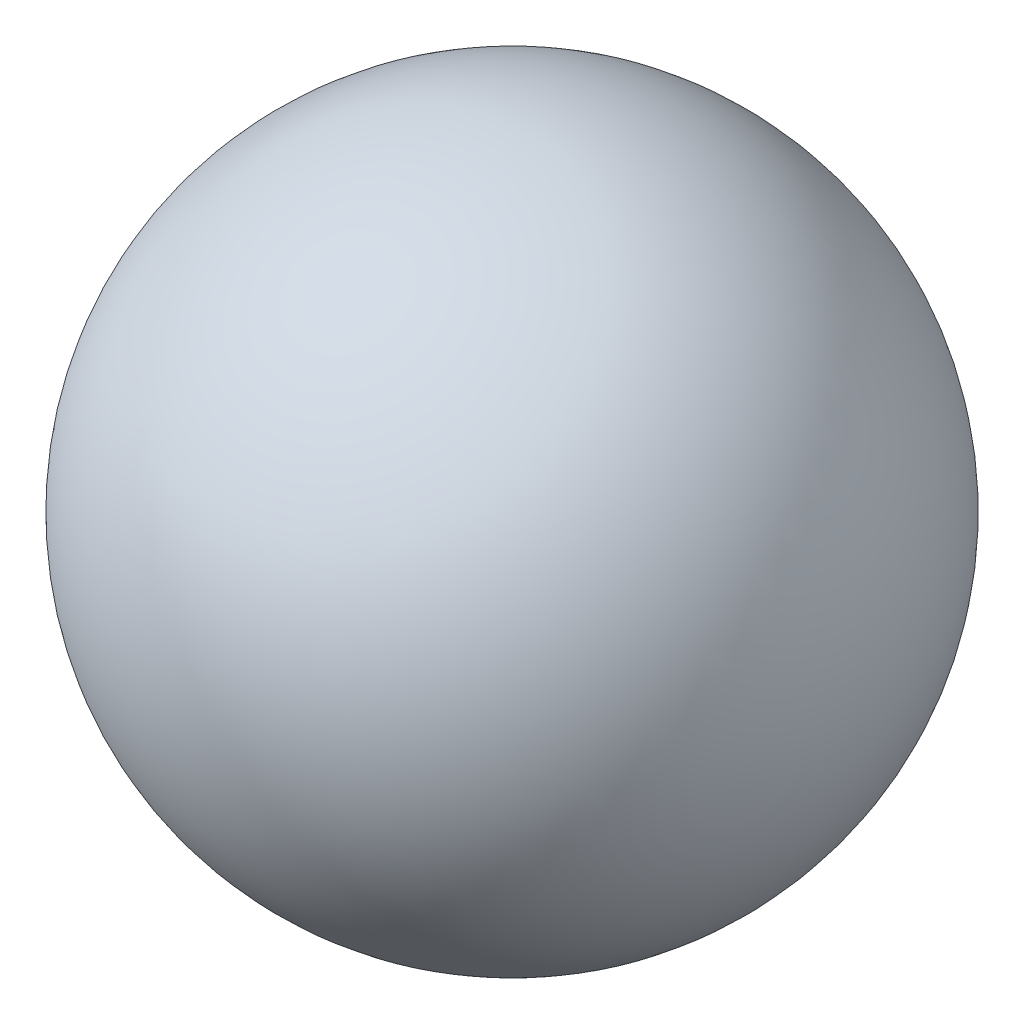
from build123d import *


with BuildPart() as part:
    # Sketch1 → Revolve1 (revolve)
    with BuildSketch(Plane.XY):
        with BuildLine():
            Line((0, 36), (0, -36))
            ThreePointArc((0, -36), (-36, 0), (0, 36))
        make_face()
    revolve(axis=Axis((0, 36, 0), (0, -1, 0)))


solid = part.part
